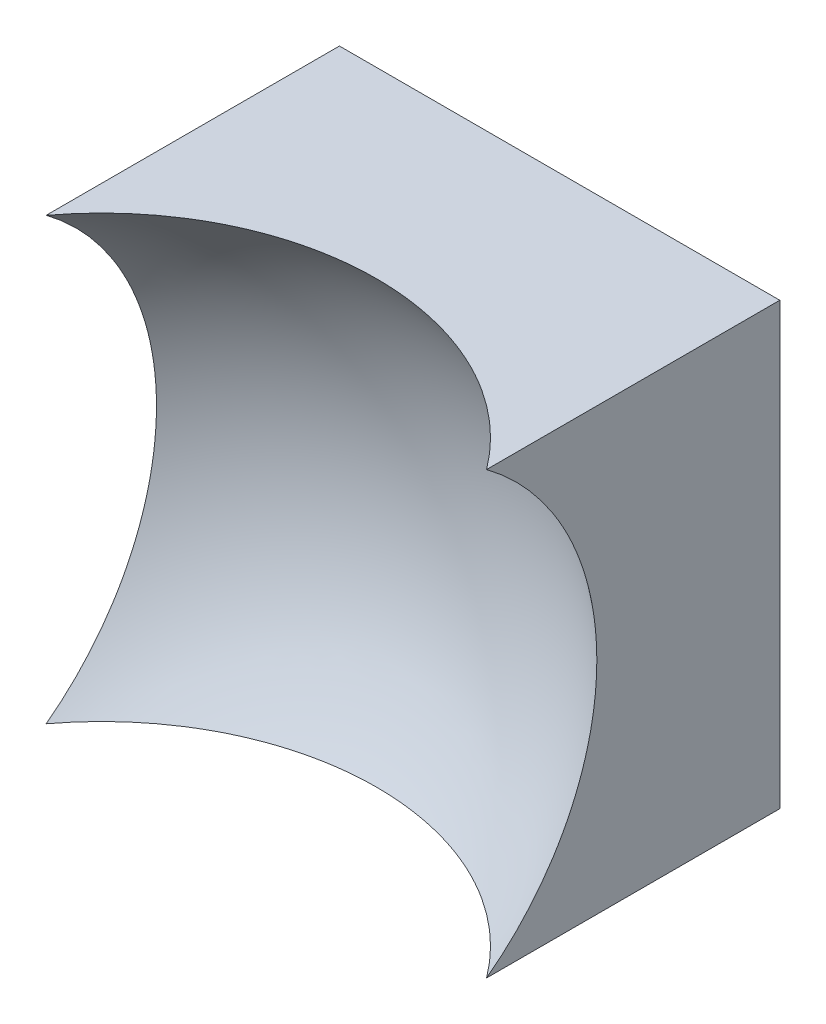
from build123d import *

# Parameters (mm, degrees)
SKETCH_1_W      = 12.5
SKETCH_1_H      = 12.5
EXTRUDE_1_DEPTH = 10


with BuildPart() as part:
    # 草图1 → 凸台-拉伸1 (new body)
    with BuildSketch(Plane.XY):
        Rectangle(SKETCH_1_W, SKETCH_1_H)
    extrude(amount=EXTRUDE_1_DEPTH)

    # 草图2 → 切除-旋转2 (revolve, cut)
    with BuildSketch(Plane(origin=(0, 0, 0), x_dir=(1, 0, 0), z_dir=(0, 1, 0))):
        with BuildLine():
            Line((9.748454618, -10.771181354), (0, -10.771181354))
            Line((0, -10.771181354), (0, -3))
            ThreePointArc((0, -3), (6.233450631, -5.180531141), (9.748454618, -10.771181354))
        make_face()
    revolve(axis=Axis((0, 0, 10.771181354), (0, 0, -1)), mode=Mode.SUBTRACT)


solid = part.part
